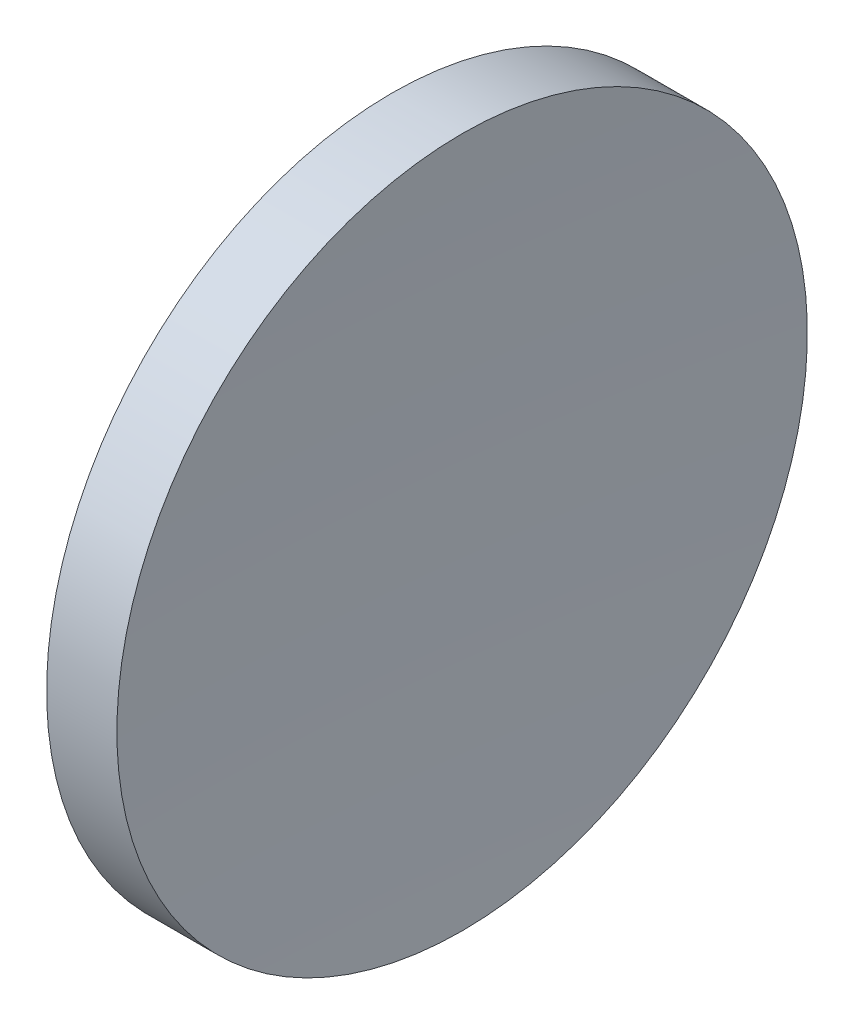
from build123d import *


with BuildPart() as part:
    # 草图1 → 旋转1 (revolve)
    with BuildSketch(Plane.XY):
        with BuildLine():
            Line((123.494374842, 77.716840471), (126.03793559, 77.716840471))
            ThreePointArc((126.03793559, 77.716840471), (125.793642992, 71.468962266), (125.712193698, 65.216840471))
            Line((125.712193698, 65.216840471), (122.612193698, 65.216840471))
            ThreePointArc((122.612193698, 65.216840471), (122.833012923, 71.482386009), (123.494374842, 77.716840471))
        make_face()
    revolve(axis=Axis((115.944491298, 65.216840471, 0), (1, 0, 0)))


solid = part.part
